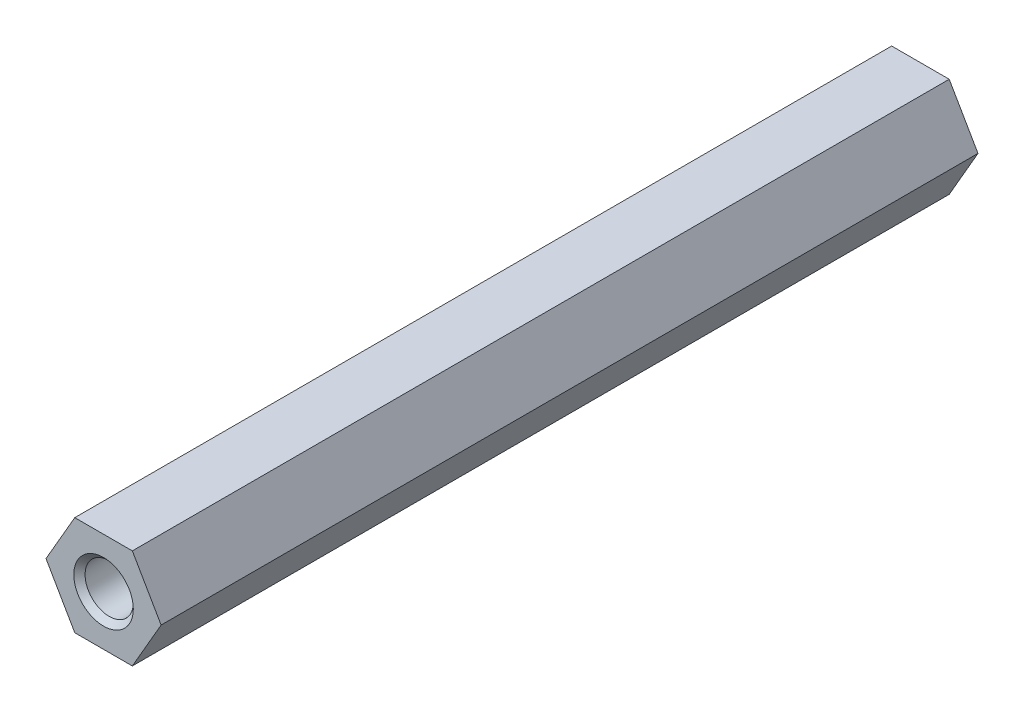
from build123d import *

# Parameters (mm, degrees)
BOSS_EXTRUDE1_DEPTH          = 50.8
F_3_0_3_DIAMETER_HOLE1_D     = 3
F_3_0_3_DIAMETER_HOLE1_DEPTH = 50.8
CHAMFER1_SIZE                = 0.35


with BuildPart() as part:
    # Sketch1 → Boss-Extrude1 (new body)
    with BuildSketch(Plane.XY.offset(50.8)):
        Polygon((-3.579571669, 0), (-1.789785834, -3.1), (1.789785834, -3.1), (3.579571669, 0), (1.789785834, 3.1), (-1.789785834, 3.1), align=None)
    extrude(amount=-BOSS_EXTRUDE1_DEPTH)

    # Ø3.0 (3) Diameter Hole1
    with Locations(Plane.XY.offset(50.8)):
        with Locations((0, 0)):
            Hole(F_3_0_3_DIAMETER_HOLE1_D / 2, depth=F_3_0_3_DIAMETER_HOLE1_DEPTH)

    # Chamfer1
    chamfer1_edges = [part.edges().sort_by_distance(p)[0] for p in [
        (1.5, 0, 50.8),
        (1.5, 0, 0),
    ]]
    chamfer(chamfer1_edges, length=CHAMFER1_SIZE)


solid = part.part
